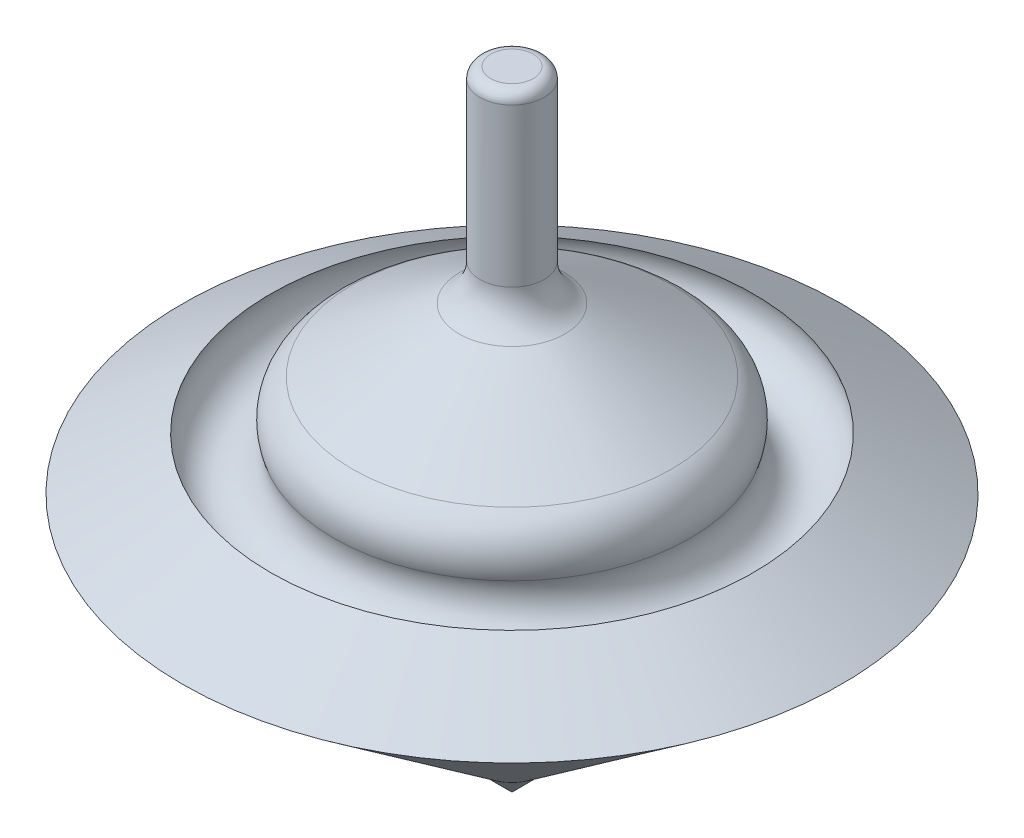
from build123d import *

# Parameters (mm, degrees)
SKETCH4_R           = 7.5
BOSS_EXTRUDE1_DEPTH = 107
SKETCH8_ONE_SIDE_R  = 7.89395432
FILLET1_R           = 10
FILLET4_R           = 2.54


with BuildPart() as part:
    # Sketch1 → Revolve1 (revolve)
    with BuildSketch(Plane.XY):
        Polygon((-6.564094159, 62.488224309), (-77.038318905, 20.431025671), (-6.564094159, -33.371877092), align=None)
    revolve(axis=Axis((0, 89.787897782, 0), (0, -1, 0)))

    # Sketch4 → Boss-Extrude1 (add)
    with BuildSketch(Plane(origin=(0, 0, 0), x_dir=(1, 0, 0), z_dir=(0, 1, 0))):
        Circle(SKETCH4_R)
    extrude(amount=BOSS_EXTRUDE1_DEPTH)

    # Sketch8 one side → Cut-Revolve1 (revolve, cut)
    with BuildSketch(Plane.XY):
        with Locations((49.128074223, 29.737990358)):
            Circle(SKETCH8_ONE_SIDE_R)
    revolve(axis=Axis((0, 59.501993736, 0), (0, -1, 0)), mode=Mode.SUBTRACT)

    # Fillet1
    fillet1_edges = [part.edges().sort_by_distance(p)[0] for p in [
        (0, 37.587323222, -48.289928414),
        (0, 61.929699856, -7.5),
    ]]
    fillet(fillet1_edges, radius=FILLET1_R)

    # Fillet4
    fillet4_edges = [part.edges().sort_by_distance(p)[0] for p in [
        (-7.5, 107, 0),
    ]]
    fillet(fillet4_edges, radius=FILLET4_R)


with BuildPart() as body_2:
    # Sketch7 → Revolve2 (revolve)
    with BuildSketch(Plane(origin=(0, 0, 0), x_dir=(0, 0, -1), z_dir=(1, 0, 0))):
        Polygon((-6.564094159, -33.371877092), (-0.289913468, -39.646057783), (-0.289913468, -33.371877092), align=None)
    revolve(axis=Axis((0, -49.303627639, 0), (0, 1, 0)))


solid = Compound([part.part, body_2.part])
